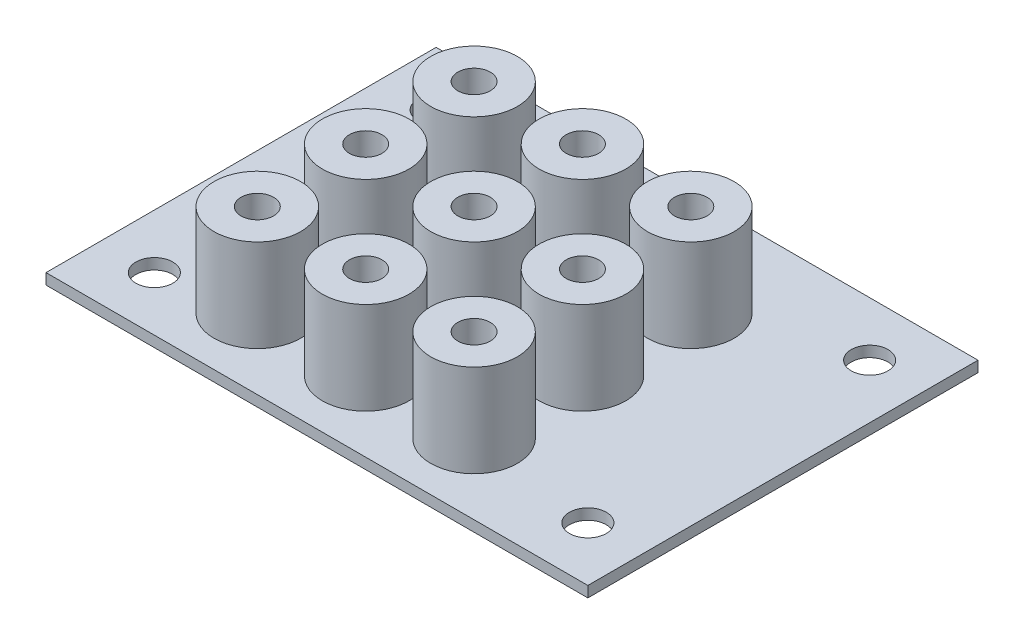
from build123d import *

# Parameters (mm, degrees)
SKETCH1_W           = 50
SKETCH1_H           = 36
SKETCH1_R           = 1.25
SKETCH1_R_2         = 1.7
BOSS_EXTRUDE1_DEPTH = 1
SKETCH2_R           = 4
SKETCH2_R_2         = 1.5
BOSS_EXTRUDE2_DEPTH = 8.525


with BuildPart() as part:
    # Sketch1 → Boss-Extrude1 (new body)
    with BuildSketch(Plane(origin=(0, 0, 0), x_dir=(1, 0, 0), z_dir=(0, 1, 0))):
        with Locations((25, 18)):
            Rectangle(SKETCH1_W, SKETCH1_H)
        with Locations((13, 6.5)):
            Circle(SKETCH1_R, mode=Mode.SUBTRACT)
        with Locations((5, 5)):
            Circle(SKETCH1_R_2, mode=Mode.SUBTRACT)
        with Locations((5, 31)):
            Circle(SKETCH1_R_2, mode=Mode.SUBTRACT)
        with Locations((45, 31)):
            Circle(SKETCH1_R_2, mode=Mode.SUBTRACT)
        with Locations((45, 5)):
            Circle(SKETCH1_R_2, mode=Mode.SUBTRACT)
        with Locations((23, 6.5)):
            Circle(SKETCH1_R, mode=Mode.SUBTRACT)
        with Locations((33, 6.5)):
            Circle(SKETCH1_R, mode=Mode.SUBTRACT)
        with Locations((23, 16.5)):
            Circle(SKETCH1_R, mode=Mode.SUBTRACT)
        with Locations((33, 16.5)):
            Circle(SKETCH1_R, mode=Mode.SUBTRACT)
        with Locations((23, 26.5)):
            Circle(SKETCH1_R, mode=Mode.SUBTRACT)
        with Locations((33, 26.5)):
            Circle(SKETCH1_R, mode=Mode.SUBTRACT)
        with Locations((13, 16.5)):
            Circle(SKETCH1_R, mode=Mode.SUBTRACT)
        with Locations((13, 26.5)):
            Circle(SKETCH1_R, mode=Mode.SUBTRACT)
    extrude(amount=BOSS_EXTRUDE1_DEPTH)

    # Sketch2 → Boss-Extrude2 (add)
    with BuildSketch(Plane(origin=(0, 1, 0), x_dir=(1, 0, 0), z_dir=(0, 1, 0))):
        with Locations((13, 26.5)):
            Circle(SKETCH2_R)
        with Locations((13, 26.5)):
            Circle(SKETCH2_R_2, mode=Mode.SUBTRACT)
        with Locations((23, 26.5)):
            Circle(SKETCH2_R)
        with Locations((23, 26.5)):
            Circle(SKETCH2_R_2, mode=Mode.SUBTRACT)
        with Locations((33, 26.5)):
            Circle(SKETCH2_R)
        with Locations((33, 26.5)):
            Circle(SKETCH2_R_2, mode=Mode.SUBTRACT)
        with Locations((23, 16.5)):
            Circle(SKETCH2_R)
        with Locations((23, 16.5)):
            Circle(SKETCH2_R_2, mode=Mode.SUBTRACT)
        with Locations((33, 16.5)):
            Circle(SKETCH2_R)
        with Locations((33, 16.5)):
            Circle(SKETCH2_R_2, mode=Mode.SUBTRACT)
        with Locations((23, 6.5)):
            Circle(SKETCH2_R)
        with Locations((23, 6.5)):
            Circle(SKETCH2_R_2, mode=Mode.SUBTRACT)
        with Locations((33, 6.5)):
            Circle(SKETCH2_R)
        with Locations((33, 6.5)):
            Circle(SKETCH2_R_2, mode=Mode.SUBTRACT)
        with Locations((13, 16.5)):
            Circle(SKETCH2_R)
        with Locations((13, 16.5)):
            Circle(SKETCH2_R_2, mode=Mode.SUBTRACT)
        with Locations((13, 6.5)):
            Circle(SKETCH2_R)
        with Locations((13, 6.5)):
            Circle(SKETCH2_R_2, mode=Mode.SUBTRACT)
    extrude(amount=BOSS_EXTRUDE2_DEPTH)


solid = part.part
